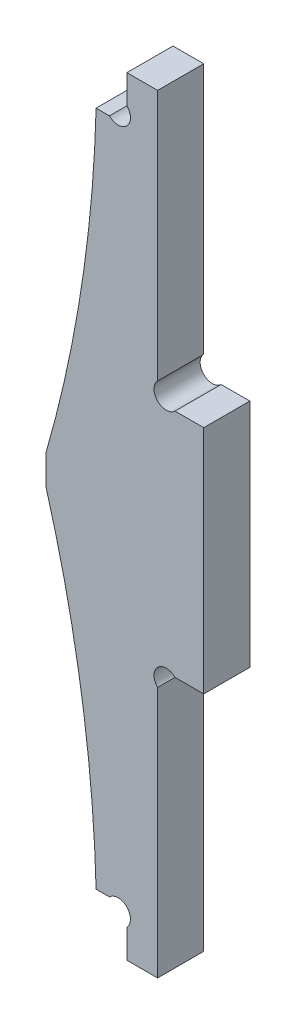
from build123d import *

# Parameters (mm, degrees)
EXTRUSION1_DEPTH = 6


with BuildPart() as part:
    # Esquisse1 → Extrusion1 (new body)
    with BuildSketch(Plane.XY):
        with BuildLine():
            Line((-14.5, 52), (-14.5, 48))
            ThreePointArc((-14.5, 48), (-9.920106606, 27.205816835), (-8, 6))
            Line((-8, 6), (-6.2627417, 6))
            ThreePointArc((-6.2627417, 6), (-4, 6), (-4, 3.7372583))
            Line((-4, 3.7372583), (-4, 0))
            Line((-4, 0), (0, 0))
            Line((0, 0), (0, 32.7372583))
            ThreePointArc((0, 32.7372583), (0, 35), (2.2627417, 35))
            Line((2.2627417, 35), (6, 35))
            Line((6, 35), (6, 65))
            Line((6, 65), (2.2627417, 65))
            ThreePointArc((2.2627417, 65), (0, 65), (0, 67.2627417))
            Line((0, 67.2627417), (0, 100))
            Line((0, 100), (-4, 100))
            Line((-4, 100), (-4, 96.2627417))
            ThreePointArc((-4, 96.2627417), (-4, 94), (-6.2627417, 94))
            Line((-6.2627417, 94), (-8, 94))
            ThreePointArc((-8, 94), (-9.920106606, 72.794183165), (-14.5, 52))
        make_face()
    extrude(amount=EXTRUSION1_DEPTH)


solid = part.part
